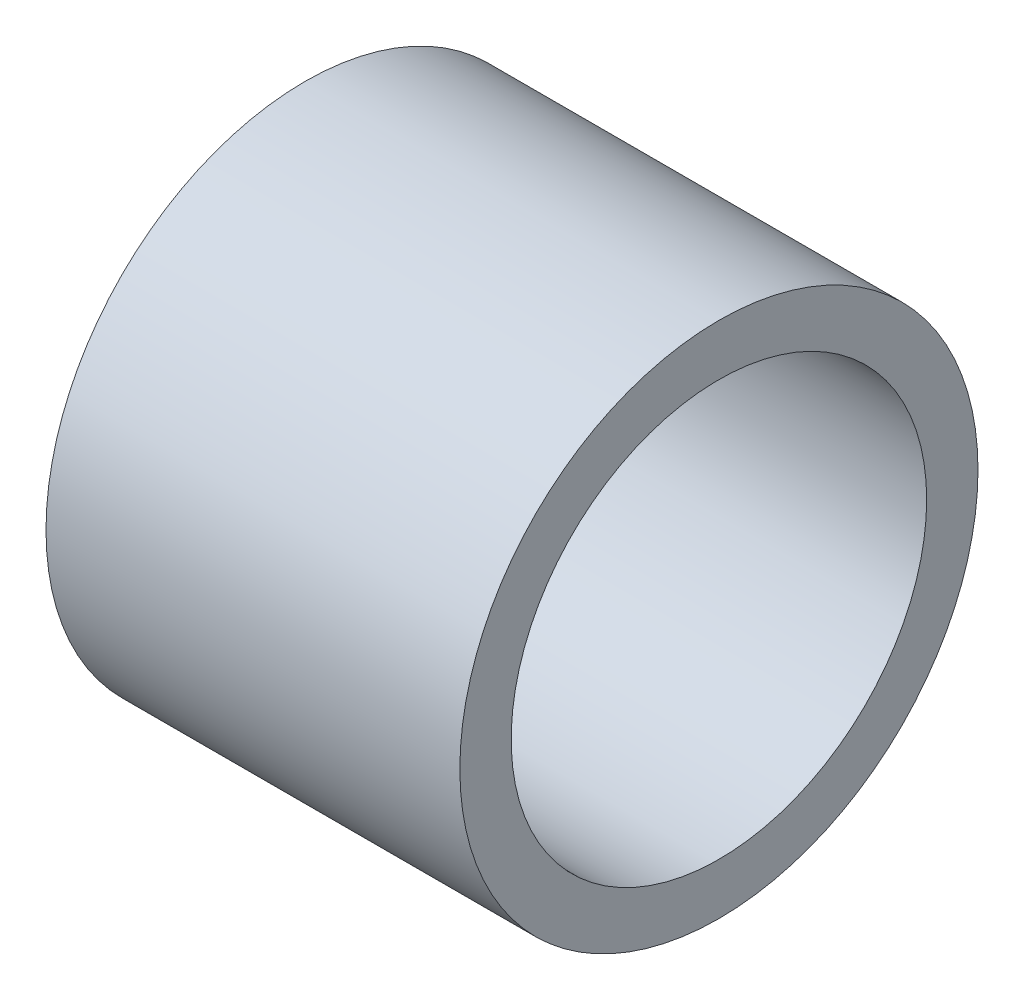
from build123d import *

# Parameters (mm, degrees)
SKETCH1_R           = 3.9751
SKETCH1_R_2         = 3.1877
BOSS_EXTRUDE1_DEPTH = 3.175


with BuildPart() as part:
    # Sketch1 → Boss-Extrude1 (new body, symmetric)
    with BuildSketch(Plane(origin=(0, 0, 0), x_dir=(0, 0, -1), z_dir=(1, 0, 0))):
        Circle(SKETCH1_R)
        Circle(SKETCH1_R_2, mode=Mode.SUBTRACT)
    extrude(amount=BOSS_EXTRUDE1_DEPTH, both=True)


solid = part.part
